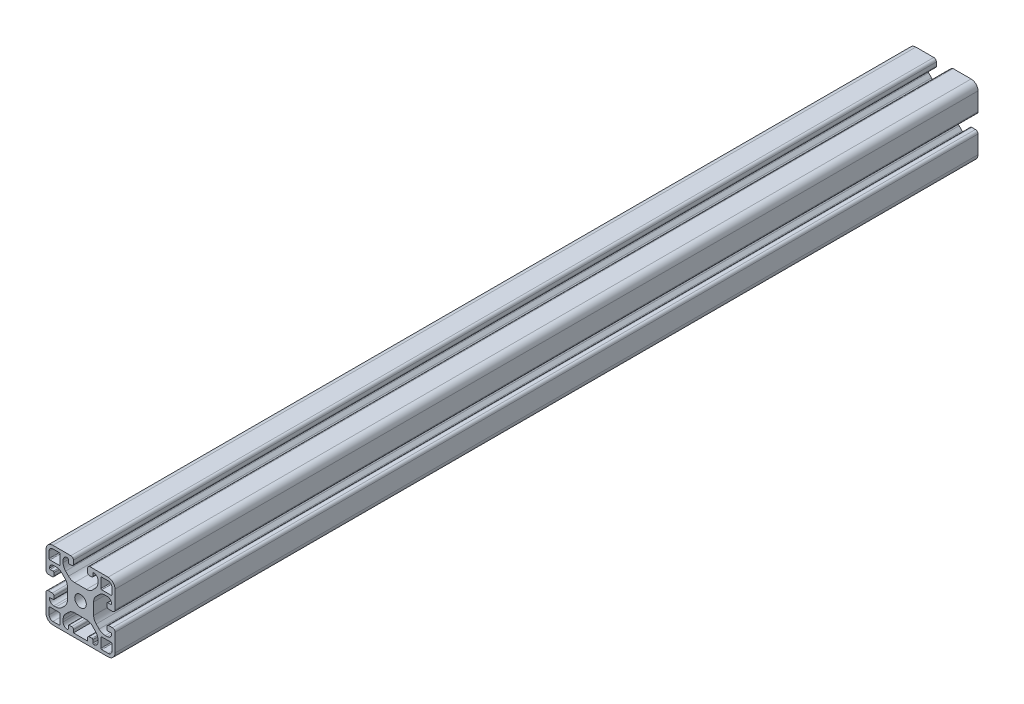
from build123d import *

# Parameters (mm, degrees)
SKIZZE1_R                       = 3.35
AUFSATZ_LINEAR_AUSTRAGEN1_DEPTH = 500


with BuildPart() as part:
    # Skizze1 → Aufsatz-Linear austragen1 (new body)
    with BuildSketch(Plane.XY.offset(1000)):
        with BuildLine():
            Line((5.899999985, 34.292388165), (5.899999985, 35.500000003))
            ThreePointArc((5.899999985, 35.500000003), (6.632233037, 37.267766961), (8.399999999, 38.000000003))
            ThreePointArc((8.399999999, 38.000000003), (8.753553388, 37.853553393), (8.899999996, 37.500000003))
            Line((8.899999996, 37.500000003), (8.899999996, 35.850000004))
            ThreePointArc((8.899999996, 35.850000004), (9.046446605, 35.496446613), (9.399999996, 35.350000004))
            Line((9.399999996, 35.350000004), (10.899999947, 35.350000004))
            ThreePointArc((10.899999947, 35.350000004), (11.607106728, 35.642893223), (11.899999947, 36.350000004))
            Line((11.899999947, 36.350000004), (11.899999947, 38.500000016))
            ThreePointArc((11.899999947, 38.500000016), (11.460660119, 39.560660188), (10.399999947, 40.000000016))
            Line((10.399999947, 40.000000016), (5.2e-08, 40.000000016))
            ThreePointArc((5.2e-08, 40.000000016), (-2.828427117, 38.828427123), (-4.000000011, 35.999999954))
            Line((-4.000000011, 35.999999954), (-4.000000011, 25.599999996))
            ThreePointArc((-4.000000011, 25.599999996), (-3.560660183, 24.539339825), (-2.500000012, 24.099999997))
            Line((-2.500000012, 24.099999997), (-0.350000011, 24.099999997))
            ThreePointArc((-0.350000011, 24.099999997), (0.35710677, 24.392893216), (0.649999989, 25.099999997))
            Line((0.649999989, 25.099999997), (0.649999989, 26.599999997))
            ThreePointArc((0.649999989, 26.599999997), (0.50355338, 26.953553387), (0.149999989, 27.099999997))
            Line((0.149999989, 27.099999997), (-1.500000011, 27.099999997))
            ThreePointArc((-1.500000011, 27.099999997), (-1.853553401, 27.246446605), (-2.000000011, 27.599999993))
            ThreePointArc((-2.000000011, 27.599999993), (-1.26776697, 29.367766957), (0.499999989, 30.10000001))
            Line((0.499999989, 30.10000001), (1.707611833, 30.10000001))
            ThreePointArc((1.707611833, 30.10000001), (3.621028995, 29.719397673), (5.243145739, 28.635533916))
            Line((5.243145739, 28.635533916), (6.935533894, 26.943145761))
            ThreePointArc((6.935533894, 26.943145761), (8.01939765, 25.321029017), (8.399999988, 23.407611855))
            Line((8.399999988, 23.407611855), (8.399999988, 16.592388122))
            ThreePointArc((8.399999988, 16.592388122), (8.01939765, 14.678970961), (6.935533894, 13.056854217))
            Line((6.935533894, 13.056854217), (5.243145737, 11.36446606))
            ThreePointArc((5.243145737, 11.36446606), (3.621028993, 10.280602303), (1.707611831, 9.899999966))
            Line((1.707611831, 9.899999966), (0.49999999, 9.899999966))
            ThreePointArc((0.49999999, 9.899999966), (-1.267766968, 10.632233018), (-2.00000001, 12.399999979))
            ThreePointArc((-2.00000001, 12.399999979), (-1.8535534, 12.753553368), (-1.50000001, 12.899999977))
            Line((-1.50000001, 12.899999977), (0.149999989, 12.899999977))
            ThreePointArc((0.149999989, 12.899999977), (0.50355338, 13.046446586), (0.649999989, 13.399999977))
            Line((0.649999989, 13.399999977), (0.649999989, 14.899999976))
            ThreePointArc((0.649999989, 14.899999976), (0.35710677, 15.607106757), (-0.350000011, 15.899999976))
            Line((-0.350000011, 15.899999976), (-2.50000001, 15.899999976))
            ThreePointArc((-2.50000001, 15.899999976), (-3.560660182, 15.460660148), (-4.000000011, 14.399999976))
            Line((-4.000000011, 14.399999976), (-4.000000011, 4.000000069))
            ThreePointArc((-4.000000011, 4.000000069), (-2.828427121, 1.171572909), (4e-08, 1.9e-08))
            Line((4e-08, 1.9e-08), (31.999999925, 1.9e-08))
            ThreePointArc((31.999999925, 1.9e-08), (34.828427086, 1.171572909), (35.999999976, 4.00000007))
            Line((35.999999976, 4.00000007), (35.999999976, 14.399999977))
            ThreePointArc((35.999999976, 14.399999977), (35.560660149, 15.460660148), (34.499999978, 15.899999976))
            Line((34.499999978, 15.899999976), (32.349999991, 15.899999976))
            ThreePointArc((32.349999991, 15.899999976), (31.642893209, 15.607106757), (31.34999999, 14.899999976))
            Line((31.34999999, 14.899999976), (31.34999999, 13.399999977))
            ThreePointArc((31.34999999, 13.399999977), (31.4964466, 13.046446586), (31.84999999, 12.899999977))
            Line((31.84999999, 12.899999977), (33.499999991, 12.899999977))
            ThreePointArc((33.499999991, 12.899999977), (33.853553381, 12.753553368), (33.999999991, 12.399999979))
            ThreePointArc((33.999999991, 12.399999979), (33.267766949, 10.632233018), (31.499999991, 9.899999966))
            Line((31.499999991, 9.899999966), (30.292388185, 9.899999966))
            ThreePointArc((30.292388185, 9.899999966), (28.378971023, 10.280602303), (26.756854279, 11.36446606))
            Line((26.756854279, 11.36446606), (25.064466082, 13.056854257))
            ThreePointArc((25.064466082, 13.056854257), (23.980602325, 14.678971001), (23.599999988, 16.592388163))
            Line((23.599999988, 16.592388163), (23.599999988, 23.407611842))
            ThreePointArc((23.599999988, 23.407611842), (23.980602325, 25.321029004), (25.064466082, 26.943145747))
            Line((25.064466082, 26.943145747), (26.75685425, 28.635533916))
            ThreePointArc((26.75685425, 28.635533916), (28.378970995, 29.719397673), (30.292388156, 30.10000001))
            Line((30.292388156, 30.10000001), (31.499999989, 30.10000001))
            ThreePointArc((31.499999989, 30.10000001), (33.267766948, 29.367766957), (33.999999989, 27.599999993))
            ThreePointArc((33.999999989, 27.599999993), (33.853553379, 27.246446605), (33.499999989, 27.099999997))
            Line((33.499999989, 27.099999997), (31.84999999, 27.099999997))
            ThreePointArc((31.84999999, 27.099999997), (31.4964466, 26.953553387), (31.34999999, 26.599999997))
            Line((31.34999999, 26.599999997), (31.34999999, 25.099999997))
            ThreePointArc((31.34999999, 25.099999997), (31.642893209, 24.392893216), (32.34999999, 24.099999997))
            Line((32.34999999, 24.099999997), (34.499999976, 24.099999997))
            ThreePointArc((34.499999976, 24.099999997), (35.560660148, 24.539339825), (35.999999976, 25.599999997))
            Line((35.999999976, 25.599999997), (35.999999976, 35.999999953))
            ThreePointArc((35.999999976, 35.999999953), (34.828427083, 38.828427123), (31.999999914, 40.000000016))
            Line((31.999999914, 40.000000016), (21.600000015, 40.000000016))
            ThreePointArc((21.600000015, 40.000000016), (20.539339844, 39.560660188), (20.100000016, 38.500000017))
            Line((20.100000016, 38.500000017), (20.100000016, 36.350000004))
            ThreePointArc((20.100000016, 36.350000004), (20.392893235, 35.642893223), (21.100000017, 35.350000004))
            Line((21.100000017, 35.350000004), (22.600000014, 35.350000004))
            ThreePointArc((22.600000014, 35.350000004), (22.953553405, 35.496446613), (23.100000014, 35.850000004))
            Line((23.100000014, 35.850000004), (23.100000014, 37.500000007))
            ThreePointArc((23.100000014, 37.500000007), (23.246446625, 37.8535534), (23.600000019, 38.000000007))
            ThreePointArc((23.600000019, 38.000000007), (25.367766955, 37.267766951), (26.099999992, 35.500000007))
            Line((26.099999992, 35.500000007), (26.099999992, 34.292388127))
            ThreePointArc((26.099999992, 34.292388127), (25.719397655, 32.378970966), (24.635533898, 30.756854221))
            Line((24.635533898, 30.756854221), (22.943145779, 29.064466103))
            ThreePointArc((22.943145779, 29.064466103), (21.321029035, 27.980602346), (19.407611873, 27.600000009))
            Line((19.407611873, 27.600000009), (12.592388142, 27.600000009))
            ThreePointArc((12.592388142, 27.600000009), (10.678970981, 27.980602346), (9.056854237, 29.064466102))
            Line((9.056854237, 29.064466102), (7.36446608, 30.75685426))
            ThreePointArc((7.36446608, 30.75685426), (6.280602323, 32.378971004), (5.899999985, 34.292388165))
        make_face()
        with Locations((15.999999985, 20)):
            Circle(SKIZZE1_R, mode=Mode.SUBTRACT)
        with BuildLine():
            Line((27.799999996, 32.299999708), (27.799999996, 37.700000083))
            ThreePointArc((27.799999996, 37.700000083), (27.946446591, 38.053553439), (28.299999947, 38.200000034))
            Line((28.299999947, 38.200000034), (31.999999914, 38.200000034))
            ThreePointArc((31.999999914, 38.200000034), (33.555634889, 37.555634929), (34.199999994, 35.999999953))
            Line((34.199999994, 35.999999953), (34.199999994, 32.300000046))
            ThreePointArc((34.199999994, 32.300000046), (34.053553382, 31.946446648), (33.699999983, 31.800000035))
            Line((33.699999983, 31.800000035), (28.299999669, 31.800000035))
            ThreePointArc((28.299999669, 31.800000035), (27.94644651, 31.946446549), (27.799999996, 32.299999708))
        make_face(mode=Mode.SUBTRACT)
        with BuildLine():
            Line((28.299999669, 8.199999998), (33.700000043, 8.199999998))
            ThreePointArc((33.700000043, 8.199999998), (34.053553399, 8.053553402), (34.199999994, 7.700000046))
            Line((34.199999994, 7.700000046), (34.199999994, 4.00000007))
            ThreePointArc((34.199999994, 4.00000007), (33.555634893, 2.444365103), (31.999999925, 1.800000001))
            Line((31.999999925, 1.800000001), (28.300000007, 1.800000001))
            ThreePointArc((28.300000007, 1.800000001), (27.946446609, 1.946446613), (27.799999996, 2.300000012))
            Line((27.799999996, 2.300000012), (27.799999996, 7.700000324))
            ThreePointArc((27.799999996, 7.700000324), (27.94644651, 8.053553484), (28.299999669, 8.199999998))
        make_face(mode=Mode.SUBTRACT)
        with BuildLine():
            Line((3.700000285, 31.800000035), (-1.700000077, 31.800000035))
            ThreePointArc((-1.700000077, 31.800000035), (-2.053553433, 31.94644663), (-2.200000029, 32.299999986))
            Line((-2.200000029, 32.299999986), (-2.200000029, 35.999999954))
            ThreePointArc((-2.200000029, 35.999999954), (-1.555634924, 37.555634929), (5.2e-08, 38.200000034))
            Line((5.2e-08, 38.200000034), (3.699999947, 38.200000034))
            ThreePointArc((3.699999947, 38.200000034), (4.053553346, 38.053553422), (4.199999959, 37.700000023))
            Line((4.199999959, 37.700000023), (4.199999959, 32.299999708))
            ThreePointArc((4.199999959, 32.299999708), (4.053553445, 31.946446549), (3.700000285, 31.800000035))
        make_face(mode=Mode.SUBTRACT)
        with BuildLine():
            Line((4.199999959, 7.700000324), (4.199999959, 2.299999952))
            ThreePointArc((4.199999959, 2.299999952), (4.053553363, 1.946446596), (3.700000007, 1.800000001))
            Line((3.700000007, 1.800000001), (4e-08, 1.800000001))
            ThreePointArc((4e-08, 1.800000001), (-1.555634927, 2.444365102), (-2.200000029, 4.000000069))
            Line((-2.200000029, 4.000000069), (-2.200000029, 7.699999986))
            ThreePointArc((-2.200000029, 7.699999986), (-2.053553416, 8.053553385), (-1.700000017, 8.199999998))
            Line((-1.700000017, 8.199999998), (3.700000285, 8.199999998))
            ThreePointArc((3.700000285, 8.199999998), (4.053553445, 8.053553484), (4.199999959, 7.700000324))
        make_face(mode=Mode.SUBTRACT)
        with BuildLine():
            Line((20.100000016, 2.000000008), (11.899999947, 2.000000008))
            Line((11.899999947, 2.000000008), (11.899999947, 3.649999992))
            ThreePointArc((11.899999947, 3.649999992), (11.607106728, 4.357106773), (10.899999947, 4.649999992))
            Line((10.899999947, 4.649999992), (9.399999996, 4.649999992))
            ThreePointArc((9.399999996, 4.649999992), (9.046446606, 4.503553382), (8.899999996, 4.149999992))
            Line((8.899999996, 4.149999992), (8.899999996, 2.499999991))
            ThreePointArc((8.899999996, 2.499999991), (8.753553389, 2.146446604), (8.400000003, 1.999999994))
            ThreePointArc((8.400000003, 1.999999994), (6.632233039, 2.732233035), (5.899999985, 4.499999994))
            Line((5.899999985, 4.499999994), (5.899999985, 5.707611838))
            ThreePointArc((5.899999985, 5.707611838), (6.280602323, 7.621029001), (7.36446608, 9.243145746))
            Line((7.36446608, 9.243145746), (9.056854238, 10.935533903))
            ThreePointArc((9.056854238, 10.935533903), (10.678970982, 12.01939766), (12.592388143, 12.399999997))
            Line((12.592388143, 12.399999997), (19.407611847, 12.399999997))
            ThreePointArc((19.407611847, 12.399999997), (21.321029008, 12.01939766), (22.943145752, 10.935533904))
            Line((22.943145752, 10.935533904), (24.635533898, 9.243145757))
            ThreePointArc((24.635533898, 9.243145757), (25.719397655, 7.621029013), (26.099999992, 5.707611851))
            Line((26.099999992, 5.707611851), (26.099999992, 4.499999993))
            ThreePointArc((26.099999992, 4.499999993), (25.367766954, 2.73223305), (23.600000019, 1.999999995))
            ThreePointArc((23.600000019, 1.999999995), (23.246446625, 2.146446603), (23.100000014, 2.499999995))
            Line((23.100000014, 2.499999995), (23.100000014, 4.149999994))
            ThreePointArc((23.100000014, 4.149999994), (22.953553405, 4.503553383), (22.600000016, 4.649999992))
            Line((22.600000016, 4.649999992), (21.100000017, 4.649999992))
            ThreePointArc((21.100000017, 4.649999992), (20.392893235, 4.357106773), (20.100000016, 3.649999992))
            Line((20.100000016, 3.649999992), (20.100000016, 2.000000008))
        make_face(mode=Mode.SUBTRACT)
    extrude(amount=-AUFSATZ_LINEAR_AUSTRAGEN1_DEPTH)


solid = part.part
